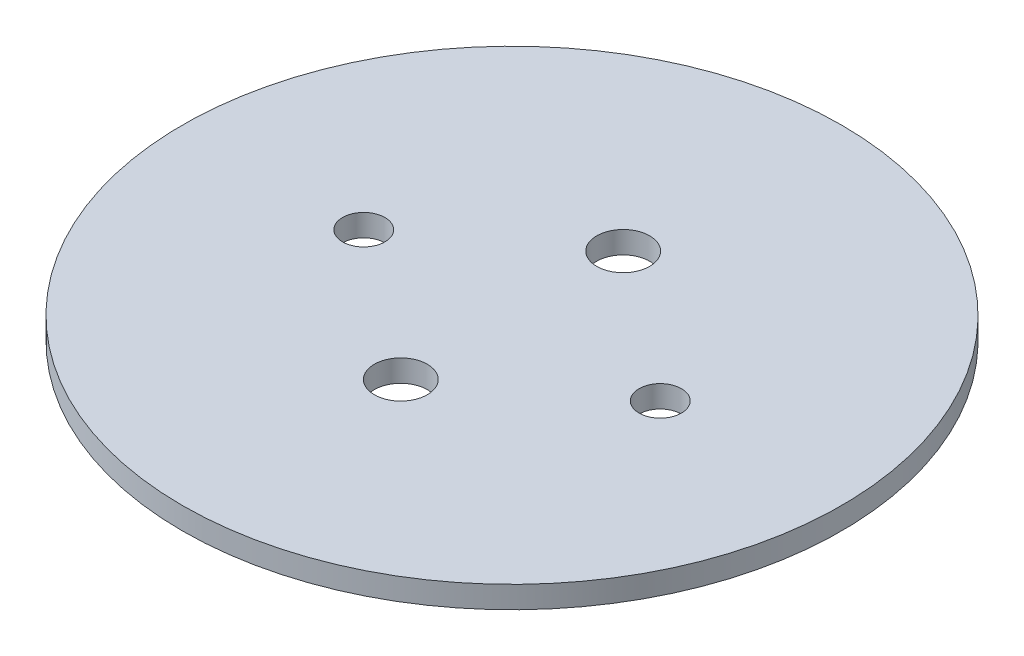
from build123d import *

# Parameters (mm, degrees)
SKETCH1_R           = 49.403
SKETCH1_R_2         = 3.175
SKETCH1_R_3         = 3.96875
BOSS_EXTRUDE1_DEPTH = 3.302


with BuildPart() as part:
    # Sketch1 → Boss-Extrude1 (new body)
    with BuildSketch(Plane(origin=(0, 0, 0), x_dir=(1, 0, 0), z_dir=(0, 1, 0))):
        Circle(SKETCH1_R)
        with Locations((22.225, 0)):
            Circle(SKETCH1_R_2, mode=Mode.SUBTRACT)
        with Locations((-22.225, 0)):
            Circle(SKETCH1_R_2, mode=Mode.SUBTRACT)
        with Locations((0, -16.66875)):
            Circle(SKETCH1_R_3, mode=Mode.SUBTRACT)
        with Locations((0, 16.66875)):
            Circle(SKETCH1_R_3, mode=Mode.SUBTRACT)
    extrude(amount=BOSS_EXTRUDE1_DEPTH)


solid = part.part
